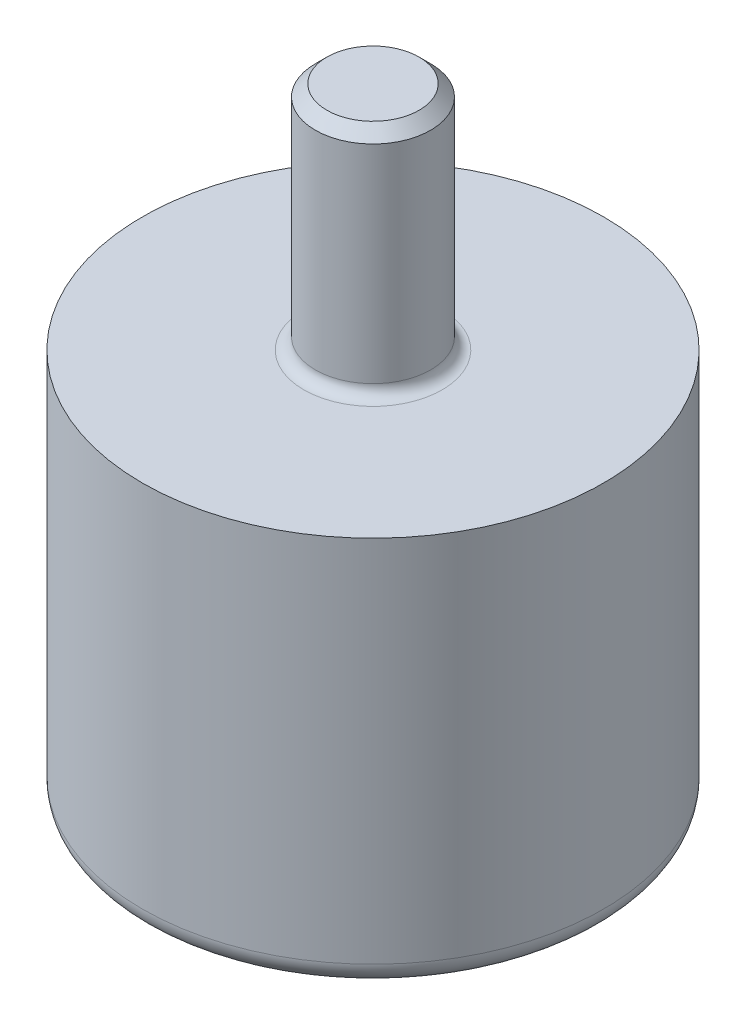
from build123d import *

# Parameters (mm, degrees)
ESQUISSE2_R      = 2.5
EXTRUSION1_DEPTH = 10
CONG_1_R         = 1
CHANFREIN1_SIZE  = 0.5
CONG_2_R         = 0.5


with BuildPart() as part:
    # Esquisse1 → Révolution1 (revolve)
    with BuildSketch(Plane.XY):
        with BuildLine():
            Line((0, 17), (10, 17))
            Line((10, 17), (10, 0))
            Line((10, 0), (5.338539126, 0))
            ThreePointArc((5.338539126, 0), (5.448623679, 6.311862178), (0, 9.5))
            Line((0, 9.5), (0, 17))
        make_face()
    revolve(axis=Axis((0, 0, 0), (0, 1, 0)))

    # Esquisse2 → Extrusion1 (add)
    with BuildSketch(Plane(origin=(0, 17, 0), x_dir=(1, 0, 0), z_dir=(0, 1, 0))):
        Circle(ESQUISSE2_R)
    extrude(amount=EXTRUSION1_DEPTH)

    # Congé1
    cong_1_edges = [part.edges().sort_by_distance(p)[0] for p in [
        (-10, 0, 0),
    ]]
    fillet(cong_1_edges, radius=CONG_1_R)

    # Chanfrein1
    chanfrein1_edges = [part.edges().sort_by_distance(p)[0] for p in [
        (-2.5, 27, 0),
    ]]
    chamfer(chanfrein1_edges, length=CHANFREIN1_SIZE)

    # Congé2
    cong_2_edges = [part.edges().sort_by_distance(p)[0] for p in [
        (-2.5, 17, 0),
    ]]
    fillet(cong_2_edges, radius=CONG_2_R)


solid = part.part
